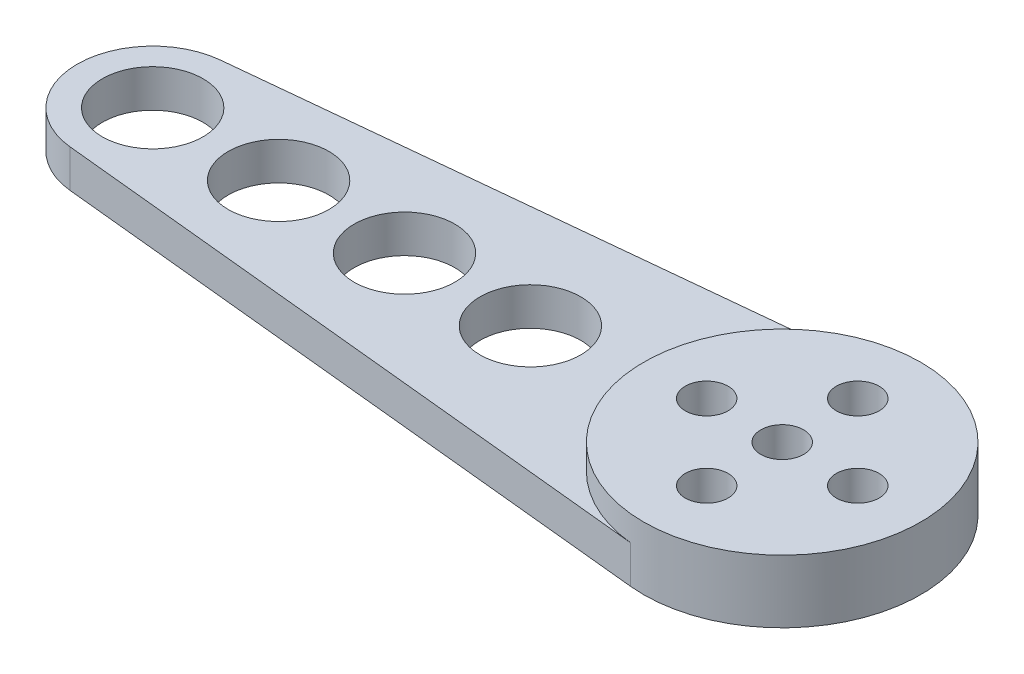
from build123d import *

# Parameters (mm, degrees)
ESQUISSE1_R             = 4
BOSS_EXTRU_1_DEPTH      = 3
ESQUISSE2_R             = 11
BOSS_EXTRU_2_DEPTH      = 2
ESQUISSE4_R             = 1.7
ENL_V_MAT_EXTRU_1_DEPTH = 6
ESQUISSE5_W             = 5.5
ESQUISSE5_H             = 5.5
ENL_V_MAT_EXTRU_2_DEPTH = 1.5


with BuildPart() as part:
    # Esquisse1 → Boss.-Extru.1 (new body)
    with BuildSketch(Plane(origin=(0, 0, 0), x_dir=(1, 0, 0), z_dir=(0, 1, 0))):
        with BuildLine():
            Line((-50.6, 5.969925), (-1.1, 10.944862))
            ThreePointArc((-1.1, 10.944862), (11, 0), (-1.1, -10.944862))
            Line((-1.1, -10.944862), (-50.6, -5.969925))
            ThreePointArc((-50.6, -5.969925), (-56, 0), (-50.6, 5.969925))
        make_face()
        with Locations((-50, 0)):
            Circle(ESQUISSE1_R, mode=Mode.SUBTRACT)
        with Locations((-40, 0)):
            Circle(ESQUISSE1_R, mode=Mode.SUBTRACT)
        with Locations((-30, 0)):
            Circle(ESQUISSE1_R, mode=Mode.SUBTRACT)
        with Locations((-20, 0)):
            Circle(ESQUISSE1_R, mode=Mode.SUBTRACT)
    extrude(amount=BOSS_EXTRU_1_DEPTH)

    # Esquisse2 → Boss.-Extru.2 (add)
    with BuildSketch(Plane(origin=(0, 3, 0), x_dir=(1, 0, 0), z_dir=(0, 1, 0))):
        Circle(ESQUISSE2_R)
    extrude(amount=BOSS_EXTRU_2_DEPTH)

    # Esquisse4 → Enlèv. mat.-Extru.1 (cut, through all)
    with BuildSketch(Plane(origin=(0, 5, 0), x_dir=(1, 0, 0), z_dir=(0, 1, 0))):
        Circle(ESQUISSE4_R)
        with Locations((0, 6)):
            Circle(ESQUISSE4_R)
        with Locations((6, 0)):
            Circle(ESQUISSE4_R)
        with Locations((0, -6)):
            Circle(ESQUISSE4_R)
        with Locations((-6, 0)):
            Circle(ESQUISSE4_R)
    extrude(amount=-ENL_V_MAT_EXTRU_1_DEPTH, mode=Mode.SUBTRACT)

    # Esquisse5 → Enlèv. mat.-Extru.2 (cut)
    with BuildSketch(Plane.XZ):
        Rectangle(ESQUISSE5_W, ESQUISSE5_H)
    extrude(amount=-ENL_V_MAT_EXTRU_2_DEPTH, mode=Mode.SUBTRACT)


solid = part.part
